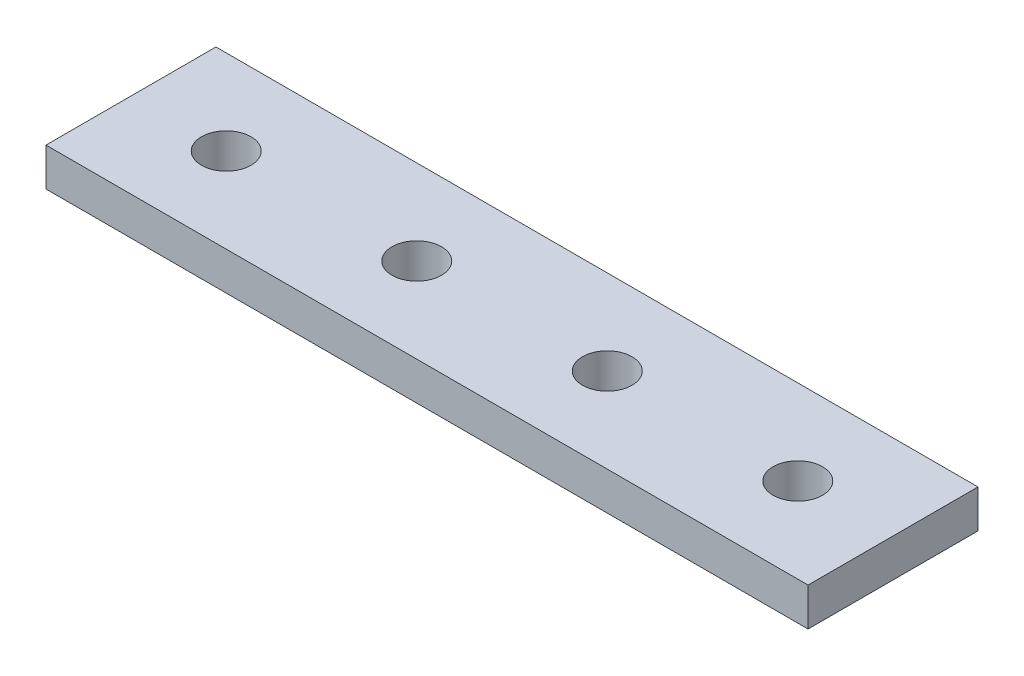
from build123d import *

# Parameters (mm, degrees)
SKETCH1_W           = 100
SKETCH1_H           = 22.3
SKETCH1_R           = 3.25
BOSS_EXTRUDE1_DEPTH = 5


with BuildPart() as part:
    # Sketch1 → Boss-Extrude1 (new body)
    with BuildSketch(Plane(origin=(0, 0, 0), x_dir=(1, 0, 0), z_dir=(0, 1, 0))):
        Rectangle(SKETCH1_W, SKETCH1_H)
        with Locations((-37.5, 0)):
            Circle(SKETCH1_R, mode=Mode.SUBTRACT)
        with Locations((-12.5, 0)):
            Circle(SKETCH1_R, mode=Mode.SUBTRACT)
        with Locations((12.5, 0)):
            Circle(SKETCH1_R, mode=Mode.SUBTRACT)
        with Locations((37.5, 0)):
            Circle(SKETCH1_R, mode=Mode.SUBTRACT)
    extrude(amount=-BOSS_EXTRUDE1_DEPTH)


solid = part.part
